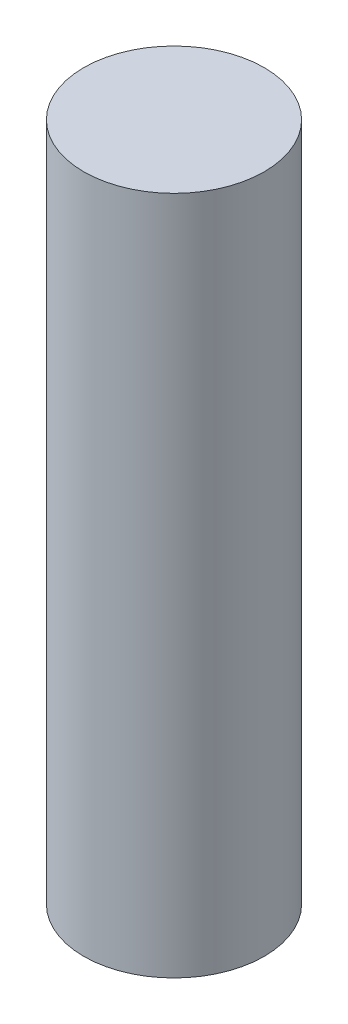
from build123d import *

# Parameters (mm, degrees)
SKETCH1_R           = 4.25
BOSS_EXTRUDE1_DEPTH = 32


with BuildPart() as part:
    # Sketch1 → Boss-Extrude1 (new body)
    with BuildSketch(Plane(origin=(0, 0, 0), x_dir=(1, 0, 0), z_dir=(0, 1, 0))):
        Circle(SKETCH1_R)
    extrude(amount=BOSS_EXTRUDE1_DEPTH)


solid = part.part
